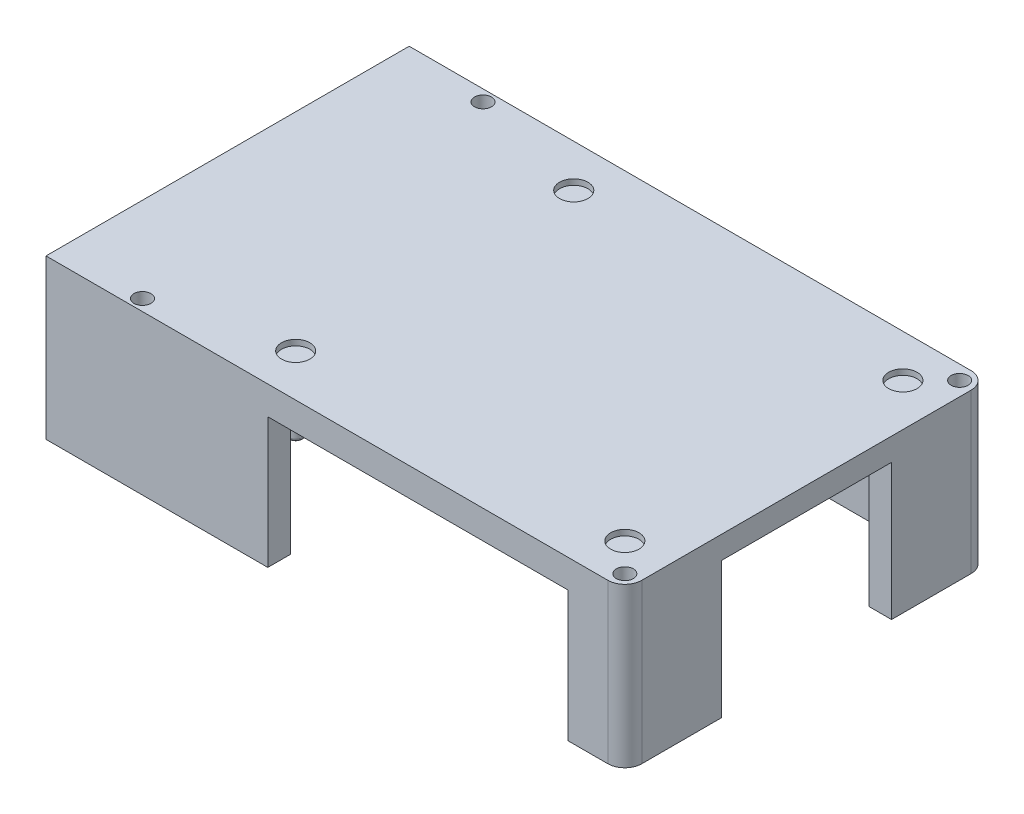
from build123d import *

# Parameters (mm, degrees)
SKETCH1_R                = 1.35
BOSS_EXTRUDE1_DEPTH      = 4
BOSS_EXTRUDE1_2_DEPTH    = 4
BOSS_EXTRUDE1_3_DEPTH    = 4
BOSS_EXTRUDE1_4_DEPTH    = 4
SKETCH1_R_2              = 2.5
BOSS_EXTRUDE1_5_DEPTH    = 4
SKETCH1_3_R              = 2.5
SKETCH1_3_R_2            = 1.35
BOSS_EXTRUDE2_DEPTH      = 4
BOSS_EXTRUDE2_2_DEPTH    = 4
BOSS_EXTRUDE2_3_DEPTH    = 4
BOSS_EXTRUDE2_4_DEPTH    = 4
SKETCH5_R                = 1.35
CUT_EXTRUDE3_DEPTH       = 5
CUT_EXTRUDE3_DEPTH_BACK  = 5
SKETCH1_4_R              = 2.5
SKETCH1_4_R_2            = 1.35
BOSS_EXTRUDE3_DEPTH      = 3
BOSS_EXTRUDE4_DEPTH      = 24
SKETCH7_W                = 58
SKETCH7_H                = 24
CUT_EXTRUDE4_DEPTH       = 9
SKETCH8_W                = 30
SKETCH8_H                = 24
CUT_EXTRUDE5_DEPTH       = 5
SKETCH13_W               = 52.913076041
SKETCH13_H               = 4
CUT_EXTRUDE6_DEPTH       = 1
CUT_EXTRUDE6_DEPTH_BACK  = 23
SKETCH1_6_R              = 1.35
BOSS_EXTRUDE5_DEPTH      = 3
BOSS_EXTRUDE5_DEPTH_BACK = 9
FILLET2_R                = 0.5
FILLET3_R                = 0.5
FILLET4_R                = 1
FILLET5_R                = 1
SKETCH15_R               = 1.5
CUT_EXTRUDE7_DEPTH       = 1
CUT_EXTRUDE7_DEPTH_BACK  = 29


with BuildPart() as part:
    # Sketch1 → Boss-Extrude1 (new body)
    with BuildSketch(Plane(origin=(0, 0, 0), x_dir=(1, 0, 0), z_dir=(0, 1, 0))):
        with Locations((-29, 24.5)):
            Circle(SKETCH1_R)
    extrude(amount=BOSS_EXTRUDE1_DEPTH)


with BuildPart() as body_2:
    # Sketch1 → Boss-Extrude1 2 (new body)
    with BuildSketch(Plane(origin=(0, 0, 0), x_dir=(1, 0, 0), z_dir=(0, 1, 0))):
        with Locations((29, 24.5)):
            Circle(SKETCH1_R)
    extrude(amount=BOSS_EXTRUDE1_2_DEPTH)


with BuildPart() as body_3:
    # Sketch1 → Boss-Extrude1 3 (new body)
    with BuildSketch(Plane(origin=(0, 0, 0), x_dir=(1, 0, 0), z_dir=(0, 1, 0))):
        with Locations((29, -24.5)):
            Circle(SKETCH1_R)
    extrude(amount=BOSS_EXTRUDE1_3_DEPTH)


with BuildPart() as body_4:
    # Sketch1 → Boss-Extrude1 4 (new body)
    with BuildSketch(Plane(origin=(0, 0, 0), x_dir=(1, 0, 0), z_dir=(0, 1, 0))):
        with Locations((-29, -24.5)):
            Circle(SKETCH1_R)
    extrude(amount=BOSS_EXTRUDE1_4_DEPTH)


with BuildPart() as body_5:
    # Sketch1 → Boss-Extrude1 5 (new body)
    with BuildSketch(Plane(origin=(0, 0, 0), x_dir=(1, 0, 0), z_dir=(0, 1, 0))):
        with BuildLine():
            Line((33.5, -32), (-65.5, -32))
            Line((-65.5, -32), (-65.5, 32))
            Line((-65.5, 32), (33.5, 32))
            ThreePointArc((33.5, 32), (35.621320344, 31.121320344), (36.5, 29))
            Line((36.5, 29), (36.5, -29))
            ThreePointArc((36.5, -29), (35.621320344, -31.121320344), (33.5, -32))
        make_face()
        with Locations((-29, 24.5)):
            Circle(SKETCH1_R_2, mode=Mode.SUBTRACT)
        with Locations((-29, -24.5)):
            Circle(SKETCH1_R_2, mode=Mode.SUBTRACT)
        with Locations((29, -24.5)):
            Circle(SKETCH1_R_2, mode=Mode.SUBTRACT)
        with Locations((29, 24.5)):
            Circle(SKETCH1_R_2, mode=Mode.SUBTRACT)
    extrude(amount=BOSS_EXTRUDE1_5_DEPTH)



with BuildPart() as body_6:
    # Sketch1_3 → Boss-Extrude2 (new body)
    with BuildSketch(Plane(origin=(0, 0, 0), x_dir=(1, 0, 0), z_dir=(0, 1, 0))):
        with Locations((-29, 24.5)):
            Circle(SKETCH1_3_R)
        with Locations((-29, 24.5)):
            Circle(SKETCH1_3_R_2, mode=Mode.SUBTRACT)
    extrude(amount=-BOSS_EXTRUDE2_DEPTH)


with BuildPart() as body_7:
    # Sketch1_3 → Boss-Extrude2 2 (new body)
    with BuildSketch(Plane(origin=(0, 0, 0), x_dir=(1, 0, 0), z_dir=(0, 1, 0))):
        with Locations((-29, -24.5)):
            Circle(SKETCH1_3_R)
        with Locations((-29, -24.5)):
            Circle(SKETCH1_3_R_2, mode=Mode.SUBTRACT)
    extrude(amount=-BOSS_EXTRUDE2_2_DEPTH)


with BuildPart() as body_8:
    # Sketch1_3 → Boss-Extrude2 3 (new body)
    with BuildSketch(Plane(origin=(0, 0, 0), x_dir=(1, 0, 0), z_dir=(0, 1, 0))):
        with Locations((29, -24.5)):
            Circle(SKETCH1_3_R)
        with Locations((29, -24.5)):
            Circle(SKETCH1_3_R_2, mode=Mode.SUBTRACT)
    extrude(amount=-BOSS_EXTRUDE2_3_DEPTH)


with BuildPart() as body_9:
    # Sketch1_3 → Boss-Extrude2 4 (new body)
    with BuildSketch(Plane(origin=(0, 0, 0), x_dir=(1, 0, 0), z_dir=(0, 1, 0))):
        with Locations((29, 24.5)):
            Circle(SKETCH1_3_R)
        with Locations((29, 24.5)):
            Circle(SKETCH1_3_R_2, mode=Mode.SUBTRACT)
    extrude(amount=-BOSS_EXTRUDE2_4_DEPTH)


with BuildPart() as cut_extrude3_tool:
    # Sketch5 → Cut-Extrude3 (new body, two sides)
    with BuildSketch(Plane.XZ) as cut_extrude3_sk:
        with Locations((-29, -24.5)):
            Circle(SKETCH5_R)
        with Locations((-29, 24.5)):
            Circle(SKETCH5_R)
        with Locations((29, 24.5)):
            Circle(SKETCH5_R)
        with Locations((29, -24.5)):
            Circle(SKETCH5_R)
    extrude(amount=CUT_EXTRUDE3_DEPTH)
    extrude(cut_extrude3_sk.sketch, amount=-CUT_EXTRUDE3_DEPTH_BACK)


with BuildPart() as part_1:
    add(part.part)

    # Cut-Extrude3: cut by cut_extrude3_tool
    add(cut_extrude3_tool.part, mode=Mode.SUBTRACT)


with BuildPart() as body_2_1:
    add(body_2.part)

    # Cut-Extrude3: cut by cut_extrude3_tool
    add(cut_extrude3_tool.part, mode=Mode.SUBTRACT)


with BuildPart() as body_3_1:
    add(body_3.part)

    # Cut-Extrude3: cut by cut_extrude3_tool
    add(cut_extrude3_tool.part, mode=Mode.SUBTRACT)


with BuildPart() as body_4_1:
    add(body_4.part)

    # Cut-Extrude3: cut by cut_extrude3_tool
    add(cut_extrude3_tool.part, mode=Mode.SUBTRACT)


with BuildPart() as body_5_1:
    add(body_5.part)

    add(body_6.part)  # Boss-Extrude3 merges body 6

    add(body_7.part)  # Boss-Extrude3 merges body 7

    add(body_8.part)  # Boss-Extrude3 merges body 8

    add(body_9.part)  # Boss-Extrude3 merges body 9
    # Sketch1_4 → Boss-Extrude3 (add)
    with BuildSketch(Plane(origin=(0, 0, 0), x_dir=(1, 0, 0), z_dir=(0, 1, 0))):
        with Locations((-29, 24.5)):
            Circle(SKETCH1_4_R)
        with Locations((-29, 24.5)):
            Circle(SKETCH1_4_R_2, mode=Mode.SUBTRACT)
        with Locations((29, 24.5)):
            Circle(SKETCH1_4_R)
        with Locations((29, 24.5)):
            Circle(SKETCH1_4_R_2, mode=Mode.SUBTRACT)
        with Locations((29, -24.5)):
            Circle(SKETCH1_4_R)
        with Locations((29, -24.5)):
            Circle(SKETCH1_4_R_2, mode=Mode.SUBTRACT)
        with Locations((-29, -24.5)):
            Circle(SKETCH1_4_R)
        with Locations((-29, -24.5)):
            Circle(SKETCH1_4_R_2, mode=Mode.SUBTRACT)
    extrude(amount=BOSS_EXTRUDE3_DEPTH)

    # Sketch1_5 → Boss-Extrude4 (add)
    with BuildSketch(Plane(origin=(0, 0, 0), x_dir=(1, 0, 0), z_dir=(0, 1, 0))):
        with BuildLine():
            Line((33.5, -32), (-65.5, -32))
            Line((-65.5, -32), (-65.5, 32))
            Line((-65.5, 32), (33.5, 32))
            ThreePointArc((33.5, 32), (35.621320344, 31.121320344), (36.5, 29))
            Line((36.5, 29), (36.5, -29))
            ThreePointArc((36.5, -29), (35.621320344, -31.121320344), (33.5, -32))
        make_face()
        with BuildLine():
            ThreePointArc((29.5, -28), (31.621320344, -27.121320344), (32.5, -25))
            Line((32.5, -25), (32.5, 25))
            ThreePointArc((32.5, 25), (31.621320344, 27.121320344), (29.5, 28))
            Line((29.5, 28), (-57.5, 28))
            Line((-57.5, 28), (-57.5, -28))
            Line((-57.5, -28), (29.5, -28))
        make_face(mode=Mode.SUBTRACT)
    extrude(amount=-BOSS_EXTRUDE4_DEPTH)

    # Sketch7 → Cut-Extrude4 (cut, through all)
    with BuildSketch(Plane(origin=(-57.5, 0, 0), x_dir=(0, 0, -1), z_dir=(1, 0, 0))):
        with Locations((0, -12)):
            Rectangle(SKETCH7_W, SKETCH7_H)
    extrude(amount=-CUT_EXTRUDE4_DEPTH, mode=Mode.SUBTRACT)

    # Sketch8 → Cut-Extrude5 (cut, through all)
    with BuildSketch(Plane.ZY.offset(-32.5)):
        with Locations((0, -12)):
            Rectangle(SKETCH8_W, SKETCH8_H)
    extrude(amount=-CUT_EXTRUDE5_DEPTH, mode=Mode.SUBTRACT)

    # Sketch13 → Cut-Extrude6 (cut, two sides)
    with BuildSketch(Plane.XZ.offset(24)) as cut_extrude6_sk:
        with Locations((0.043461979, 30)):
            Rectangle(SKETCH13_W, SKETCH13_H)
    extrude(amount=CUT_EXTRUDE6_DEPTH, mode=Mode.SUBTRACT)
    extrude(cut_extrude6_sk.sketch, amount=-CUT_EXTRUDE6_DEPTH_BACK, mode=Mode.SUBTRACT)

    # Sketch1_6 → Boss-Extrude5 (add, two sides)
    with BuildSketch(Plane(origin=(0, 0, 0), x_dir=(1, 0, 0), z_dir=(0, 1, 0))) as boss_extrude5_sk:
        with Locations((29, 24.5)):
            Circle(SKETCH1_6_R)
        with Locations((-29, 24.5)):
            Circle(SKETCH1_6_R)
        with Locations((-29, -24.5)):
            Circle(SKETCH1_6_R)
        with Locations((29, -24.5)):
            Circle(SKETCH1_6_R)
    extrude(amount=BOSS_EXTRUDE5_DEPTH)
    extrude(boss_extrude5_sk.sketch, amount=-BOSS_EXTRUDE5_DEPTH_BACK)

    # Fillet2
    fillet2_edges = [body_5_1.edges().sort_by_distance(p)[0] for p in [
        (27.65, -9, 24.5),
    ]]
    fillet(fillet2_edges, radius=FILLET2_R)

    # Fillet3
    fillet3_edges = [body_5_1.edges().sort_by_distance(p)[0] for p in [
        (27.65, -9, -24.5),
        (-30.35, -9, -24.5),
        (-30.35, -9, 24.5),
    ]]
    fillet(fillet3_edges, radius=FILLET3_R)

    # Fillet4
    fillet4_edges = [body_5_1.edges().sort_by_distance(p)[0] for p in [
        (-31.5, -4, -24.5),
    ]]
    fillet(fillet4_edges, radius=FILLET4_R)

    # Fillet5
    fillet5_edges = [body_5_1.edges().sort_by_distance(p)[0] for p in [
        (26.5, -4, -24.5),
        (26.5, -4, 24.5),
        (-31.5, -4, 24.5),
    ]]
    fillet(fillet5_edges, radius=FILLET5_R)

    # Sketch15 → Cut-Extrude7 (cut, two sides)
    with BuildSketch(Plane.XZ.offset(24)) as cut_extrude7_sk:
        with Locations((34, -29.5)):
            Circle(SKETCH15_R)
        with Locations((34, 29.5)):
            Circle(SKETCH15_R)
        with Locations((-50.5, 30)):
            Circle(SKETCH15_R)
        with Locations((-50.5, -30)):
            Circle(SKETCH15_R)
    extrude(amount=CUT_EXTRUDE7_DEPTH, mode=Mode.SUBTRACT)
    extrude(cut_extrude7_sk.sketch, amount=-CUT_EXTRUDE7_DEPTH_BACK, mode=Mode.SUBTRACT)


solid = body_5_1.part
